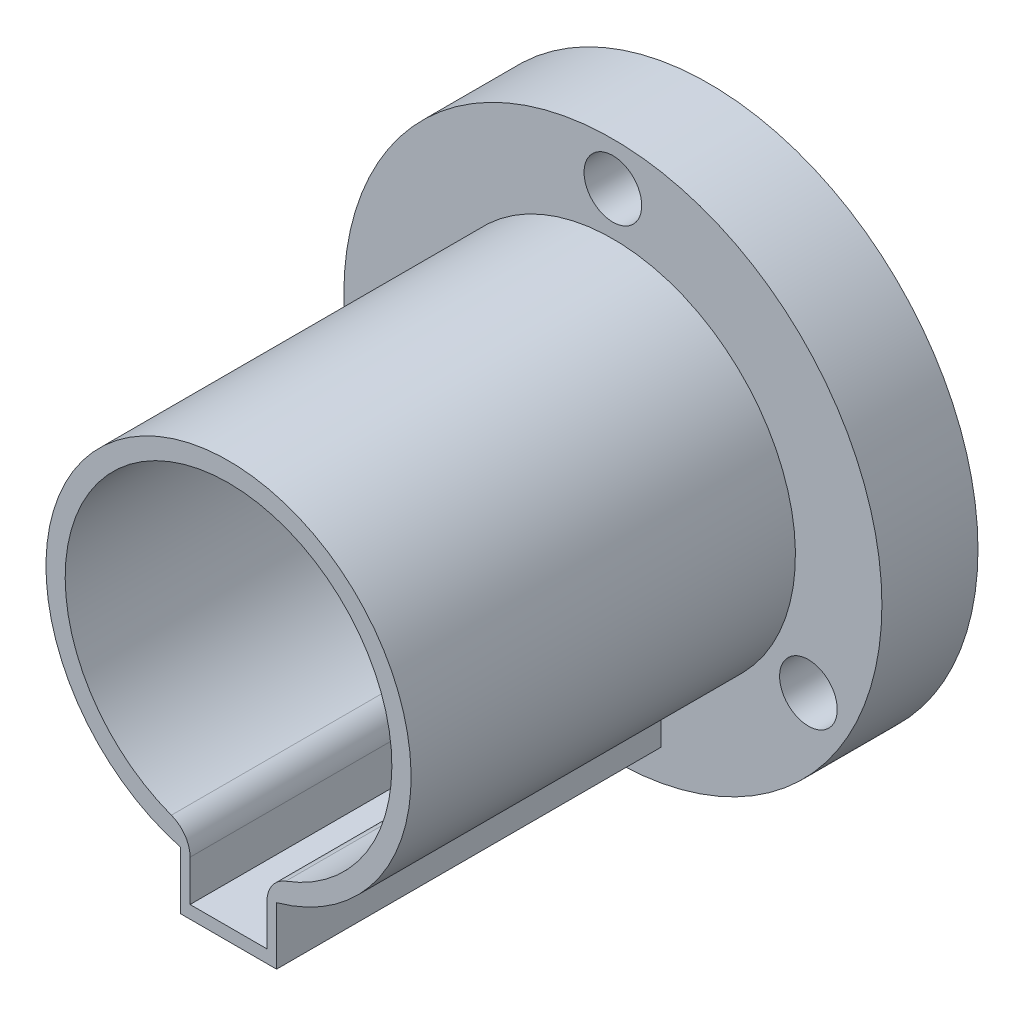
from build123d import *

# Parameters (mm, degrees)
SKETCH1_R           = 14
BOSS_EXTRUDE1_DEPTH = 5
BOSS_EXTRUDE3_DEPTH = 20
SKETCH3_R           = 8.5
CUT_EXTRUDE1_DEPTH  = 26
SKETCH5_W           = 4
SKETCH5_H           = 11.5
CUT_EXTRUDE3_DEPTH  = 26
SKETCH6_R           = 1.5
CUT_EXTRUDE4_DEPTH  = 6
CIRPATTERN1_COUNT   = 3
FILLET1_R           = 1.5


with BuildPart() as part:
    # Sketch1 → Boss-Extrude1 (new body)
    with BuildSketch(Plane.XY):
        Circle(SKETCH1_R)
    extrude(amount=BOSS_EXTRUDE1_DEPTH)

    # Sketch2 → Boss-Extrude3 (add)
    with BuildSketch(Plane.XY.offset(5)):
        with BuildLine():
            Line((2.5, -9.16515139), (2.5, -12.16515139))
            Line((2.5, -12.16515139), (-2.5, -12.16515139))
            Line((-2.5, -12.16515139), (-2.5, -9.16515139))
            ThreePointArc((-2.5, -9.16515139), (0, 9.5), (2.5, -9.16515139))
        make_face()
    extrude(amount=BOSS_EXTRUDE3_DEPTH)

    # Sketch3 → Cut-Extrude1 (cut, through all)
    with BuildSketch(Plane.XY.offset(25)):
        Circle(SKETCH3_R)
    extrude(amount=-CUT_EXTRUDE1_DEPTH, mode=Mode.SUBTRACT)

    # Sketch5 → Cut-Extrude3 (cut, through all)
    with BuildSketch(Plane.XY.offset(25)):
        with Locations((0, -5.75)):
            Rectangle(SKETCH5_W, SKETCH5_H)
    extrude(amount=-CUT_EXTRUDE3_DEPTH, mode=Mode.SUBTRACT)

    # Sketch6 → Cut-Extrude4 (cut, through all)
    with BuildSketch(Plane.XY.offset(5)):
        with Locations((0, 11.75)):
            Circle(SKETCH6_R)
    cut_extrude4 = extrude(amount=-CUT_EXTRUDE4_DEPTH, mode=Mode.SUBTRACT)

    # CirPattern1: Cut-Extrude4 ×3 about axis
    cirpattern1_axis = Axis((0, 0, 0), (0, 0, 1))
    for i in range(1, CIRPATTERN1_COUNT):
        add(cut_extrude4.rotate(cirpattern1_axis, i * 360 / CIRPATTERN1_COUNT), mode=Mode.SUBTRACT)

    # Fillet1
    fillet1_edges = [part.edges().sort_by_distance(p)[0] for p in [
        (2, -8.261355821, 12.5),
        (-2, -8.261355821, 12.5),
    ]]
    fillet(fillet1_edges, radius=FILLET1_R)


solid = part.part
